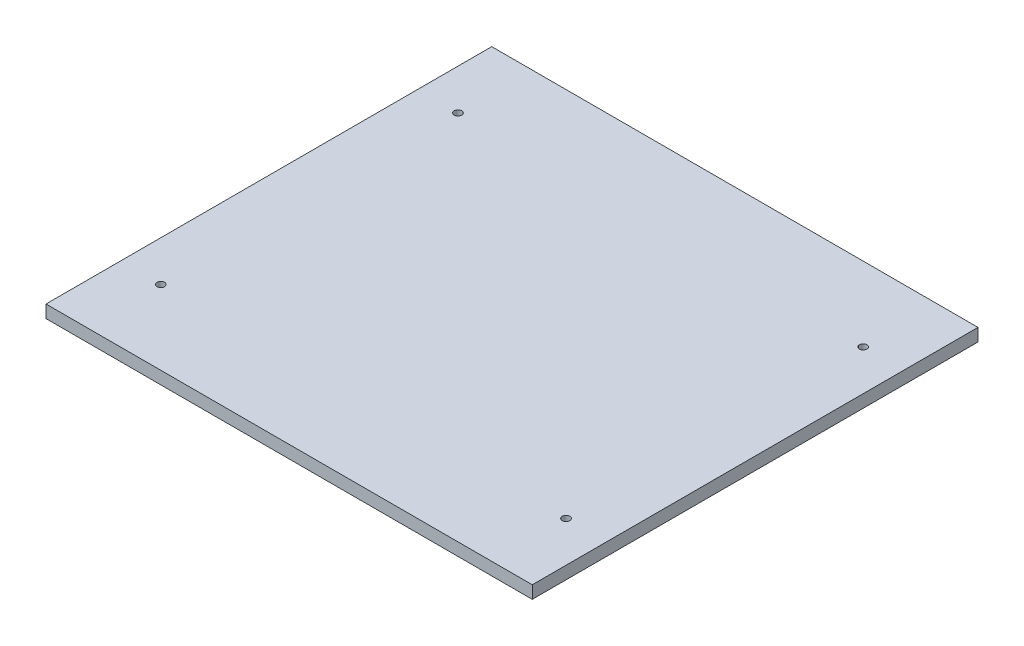
from build123d import *

# Parameters (mm, degrees)
SKETCH1_W                       = 457.2
SKETCH1_H                       = 419.1
BOSS_EXTRUDE1_DEPTH             = 11.90625
F_9_32_0_28125_DIAMETER_HOLE1_D = 7.14375


with BuildPart() as part:
    # Sketch1 → Boss-Extrude1 (new body)
    with BuildSketch(Plane(origin=(0, 0, 0), x_dir=(1, 0, 0), z_dir=(0, 1, 0))):
        Rectangle(SKETCH1_W, SKETCH1_H)
    extrude(amount=BOSS_EXTRUDE1_DEPTH)

    # 9/32 (0.28125) Diameter Hole1 (through all)
    with Locations(Plane(origin=(0, 11.90625, 0), x_dir=(1, 0, 0), z_dir=(0, 1, 0))):
        with Locations((-190.5, 139.7), (190.5, 139.7), (190.5, -139.7), (-190.5, -139.7)):
            Hole(F_9_32_0_28125_DIAMETER_HOLE1_D / 2)


solid = part.part
